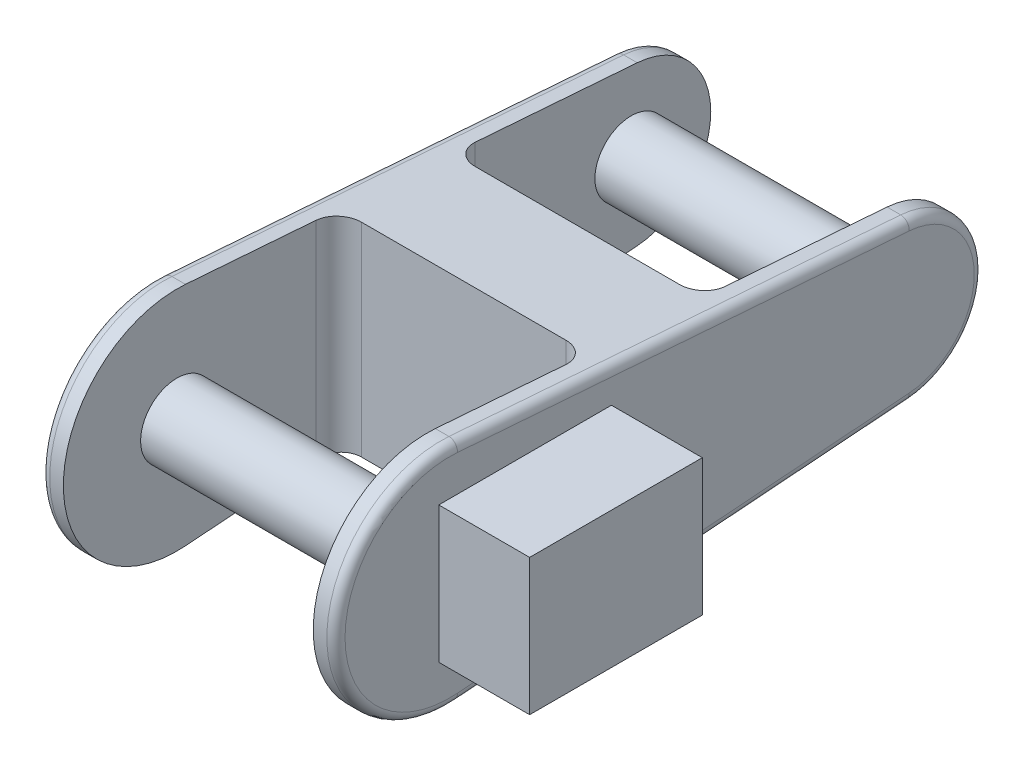
from build123d import *

# Parameters (mm, degrees)
BOSS_EXTRUDE1_DEPTH = 32.5
SKETCH2_W           = 55
SKETCH2_H           = 56.864750755
SKETCH2_H_2         = 60.635249245
CUT_EXTRUDE1_DEPTH  = 32.5
SKETCH4_R           = 8
BOSS_EXTRUDE2_DEPTH = 55
SKETCH5_W           = 38
SKETCH5_H           = 30
BOSS_EXTRUDE3_DEPTH = 20
SKETCH6_R           = 3
BOSS_EXTRUDE4_DEPTH = 3
FILLET1_R           = 2
FILLET3_R           = 2
FILLET5_R           = 5
FILLET6_R           = 5
FILLET7_R           = 5
FILLET8_R           = 5


with BuildPart() as part:
    # Sketch1 → Boss-Extrude1 (new body, symmetric)
    with BuildSketch(Plane(origin=(0, 0, 0), x_dir=(0, 0, -1), z_dir=(1, 0, 0))):
        with BuildLine():
            Line((1.875, -24.929588344), (101.3125, -17.450711841))
            ThreePointArc((101.3125, -17.450711841), (117.5, 0), (101.3125, 17.450711841))
            Line((101.3125, 17.450711841), (1.875, 24.929588344))
            ThreePointArc((1.875, 24.929588344), (-25, 0), (1.875, -24.929588344))
        make_face()
    extrude(amount=BOSS_EXTRUDE1_DEPTH, both=True)

    # Sketch2 → Cut-Extrude1 (cut, symmetric)
    with BuildSketch(Plane(origin=(0, 0, 0), x_dir=(1, 0, 0), z_dir=(0, 1, 0))):
        with Locations((0, 89.067624623)):
            Rectangle(SKETCH2_W, SKETCH2_H)
        with Locations((0, 5.317624623)):
            Rectangle(SKETCH2_W, SKETCH2_H_2)
    extrude(amount=CUT_EXTRUDE1_DEPTH, both=True, mode=Mode.SUBTRACT)

    # Sketch4 → Boss-Extrude2 (add)
    with BuildSketch(Plane(origin=(-27.5, 0, 0), x_dir=(0, 0, -1), z_dir=(1, 0, 0))):
        Circle(SKETCH4_R)
        with Locations((100, 0)):
            Circle(SKETCH4_R)
    extrude(amount=BOSS_EXTRUDE2_DEPTH)

    # Sketch5 → Boss-Extrude3 (add)
    with BuildSketch(Plane(origin=(32.5, 0, 0), x_dir=(0, 0, -1), z_dir=(1, 0, 0))):
        with Locations((16.635249245, 0)):
            Rectangle(SKETCH5_W, SKETCH5_H)
    extrude(amount=BOSS_EXTRUDE3_DEPTH)

    # Sketch6 → Boss-Extrude4 (add)
    with BuildSketch(Plane(origin=(0, 0, -35.635249245), x_dir=(-1, 0, 0), z_dir=(0, 0, -1))):
        with Locations((-42.5, 8)):
            Circle(SKETCH6_R)
        with Locations((-42.5, -8)):
            Circle(SKETCH6_R)
    extrude(amount=BOSS_EXTRUDE4_DEPTH)

    # Fillet1
    fillet1_edges = [part.edges().sort_by_distance(p)[0] for p in [
        (32.5, 0, -117.5),
        (32.5, 21.190150092, -51.59375),
        (32.5, 0, 25),
        (32.5, -21.190150092, -51.59375),
    ]]
    fillet(fillet1_edges, radius=FILLET1_R)

    # Fillet3
    fillet3_edges = [part.edges().sort_by_distance(p)[0] for p in [
        (-32.5, 21.190150092, -51.59375),
        (-32.5, 0, -117.5),
        (-32.5, -21.190150092, -51.59375),
        (-32.5, 0, 25),
    ]]
    fillet(fillet3_edges, radius=FILLET3_R)

    # Fillet5
    fillet5_edges = [part.edges().sort_by_distance(p)[0] for p in [
        (27.5, 0, -60.635249245),
    ]]
    fillet(fillet5_edges, radius=FILLET5_R)

    # Fillet6
    fillet6_edges = [part.edges().sort_by_distance(p)[0] for p in [
        (-27.5, 0, -60.635249245),
    ]]
    fillet(fillet6_edges, radius=FILLET6_R)

    # Fillet7
    fillet7_edges = [part.edges().sort_by_distance(p)[0] for p in [
        (-27.5, 0, -35.635249245),
    ]]
    fillet(fillet7_edges, radius=FILLET7_R)

    # Fillet8
    fillet8_edges = [part.edges().sort_by_distance(p)[0] for p in [
        (27.5, 0, -35.635249245),
    ]]
    fillet(fillet8_edges, radius=FILLET8_R)


solid = part.part
